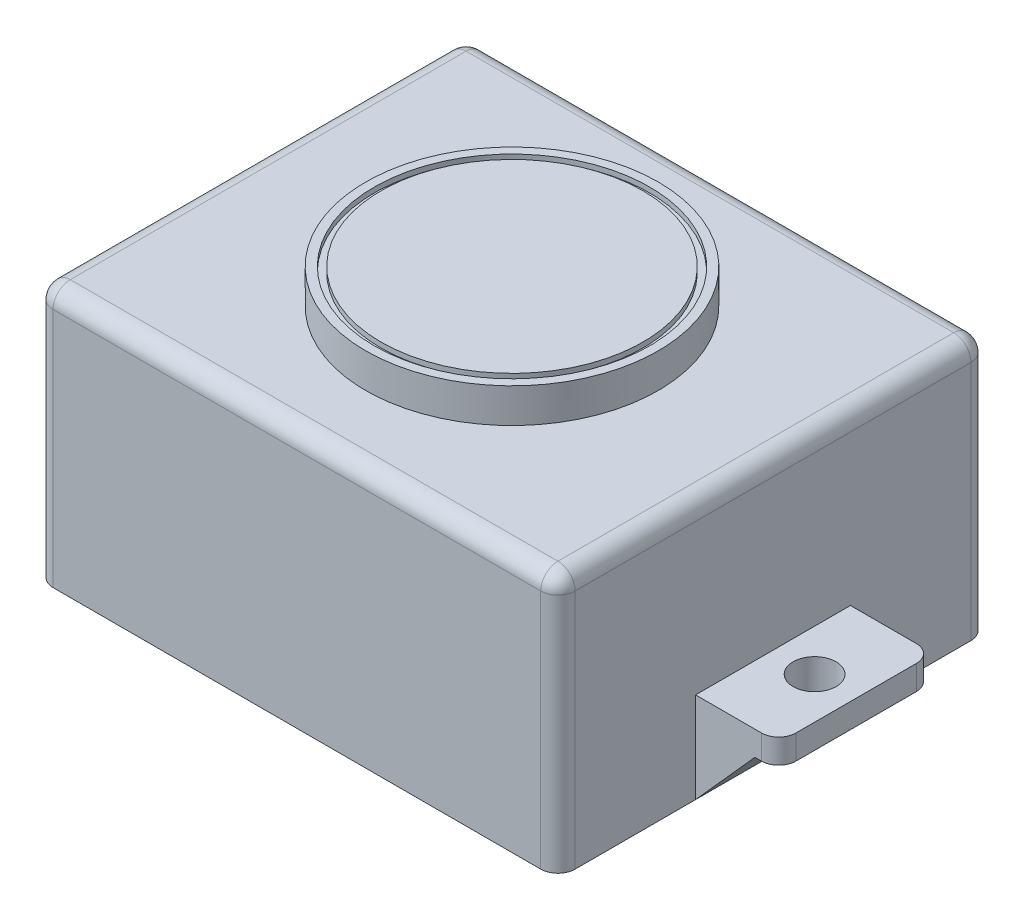
from build123d import *

# Parameters (mm, degrees)
BOSS_EXTRUDE1_DEPTH = 635
SKETCH2_W           = 122.70945946
SKETCH2_H           = 203.2
SKETCH2_W_2         = 122.709459459
CUT_EXTRUDE1_DEPTH  = 382
SKETCH3_R           = 31.75
CUT_EXTRUDE2_DEPTH  = 88.9
FILLET1_R           = 25.4
FILLET2_R           = 25.4
SKETCH4_R           = 215.9
BOSS_EXTRUDE2_DEPTH = 50.8
SKETCH5_R           = 203.2
CUT_EXTRUDE3_DEPTH  = 7.62
SKETCH6_R           = 193.397530636
BOSS_EXTRUDE3_DEPTH = 7.62
SCALE1_SCALE        = 0.01


with BuildPart() as part:
    # Sketch1 → Boss-Extrude1 (new body)
    with BuildSketch(Plane.XY):
        Polygon((-503.923986486, 236.837837838), (266.657094595, 236.837837838), (266.657094595, -10.297297297), (389.366554054, -10.297297297), (389.366554054, -46.337837838), (354.184121622, -46.337837838), (266.657094595, -144.162162162), (-503.923986486, -144.162162162), (-591.451013514, -46.337837838), (-626.633445946, -46.337837838), (-626.633445946, -10.297297297), (-503.923986486, -10.297297297), align=None)
    extrude(amount=BOSS_EXTRUDE1_DEPTH)

    # Sketch2 → Cut-Extrude1 (cut, through all)
    with BuildSketch(Plane(origin=(0, 236.837837838, 0), x_dir=(1, 0, 0), z_dir=(0, 1, 0))):
        with Locations((-565.278716216, -101.6)):
            Rectangle(SKETCH2_W, SKETCH2_H)
        with Locations((-565.278716216, -533.4)):
            Rectangle(SKETCH2_W, SKETCH2_H)
        with Locations((328.011824325, -533.4)):
            Rectangle(SKETCH2_W_2, SKETCH2_H)
        with Locations((328.011824325, -101.6)):
            Rectangle(SKETCH2_W_2, SKETCH2_H)
    extrude(amount=-CUT_EXTRUDE1_DEPTH, mode=Mode.SUBTRACT)

    # Sketch3 → Cut-Extrude2 (cut)
    with BuildSketch(Plane(origin=(0, -10.297297297, 0), x_dir=(1, 0, 0), z_dir=(0, 1, 0))):
        with Locations((-565.278716216, -317.5)):
            Circle(SKETCH3_R)
        with Locations((328.011824324, -317.5)):
            Circle(SKETCH3_R)
    extrude(amount=-CUT_EXTRUDE2_DEPTH, mode=Mode.SUBTRACT)

    # Fillet1
    fillet1_edges = [part.edges().sort_by_distance(p)[0] for p in [
        (389.366554054, -28.317567568, 203.2),
        (389.366554054, -28.317567568, 431.8),
        (-626.633445946, -28.317567568, 431.8),
        (-626.633445946, -28.317567568, 203.2),
    ]]
    fillet(fillet1_edges, radius=FILLET1_R)

    # Fillet2
    fillet2_edges = [part.edges().sort_by_distance(p)[0] for p in [
        (-503.923986486, 46.337837838, 0),
        (-118.633445946, 236.837837838, 0),
        (266.657094595, 46.337837838, 0),
        (-503.923986486, 236.837837838, 317.5),
        (266.657094595, 236.837837838, 317.5),
        (266.657094595, 46.337837838, 635),
        (-118.633445946, 236.837837838, 635),
        (-503.923986486, 46.337837838, 635),
    ]]
    fillet(fillet2_edges, radius=FILLET2_R)

    # Sketch4 → Boss-Extrude2 (add)
    with BuildSketch(Plane(origin=(0, 236.837837838, 0), x_dir=(1, 0, 0), z_dir=(0, 1, 0))):
        with Locations((-118.633445946, -317.5)):
            Circle(SKETCH4_R)
    extrude(amount=BOSS_EXTRUDE2_DEPTH)

    # Sketch5 → Cut-Extrude3 (cut)
    with BuildSketch(Plane(origin=(0, 287.637837838, 0), x_dir=(1, 0, 0), z_dir=(0, 1, 0))):
        with Locations((-118.633445946, -317.5)):
            Circle(SKETCH5_R)
    extrude(amount=-CUT_EXTRUDE3_DEPTH, mode=Mode.SUBTRACT)


with BuildPart() as body_2:
    # Sketch6 → Boss-Extrude3 (new body)
    with BuildSketch(Plane(origin=(0, 280.017837838, 0), x_dir=(1, 0, 0), z_dir=(0, 1, 0))):
        with Locations((-118.633445946, -317.5)):
            Circle(SKETCH6_R)
    extrude(amount=BOSS_EXTRUDE3_DEPTH)


with BuildPart() as body_2_1:
    # Scale1: scaled about (0, 0, 0)
    add(body_2.part.scale(SCALE1_SCALE))


with BuildPart() as part_1:
    # Scale1: scaled about (0, 0, 0)
    add(part.part.scale(SCALE1_SCALE))


solid = Compound([body_2_1.part, part_1.part])
